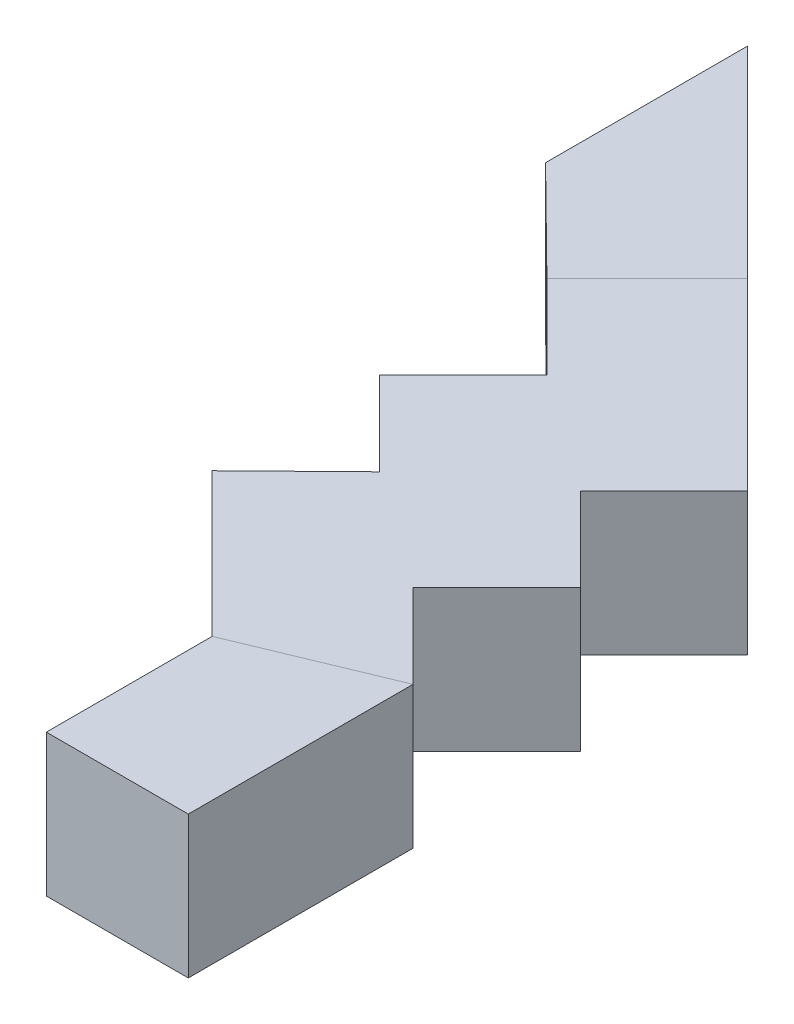
from build123d import *

# Parameters (mm, degrees)
BOSS_EXTRUDE1_DEPTH      = 600
CUT_EXTRUDE9_DEPTH       = 8723.868006427
CUT_EXTRUDE9_DEPTH_BACK  = 8723.868006427
CUT_EXTRUDE_THIN1_DEPTH  = 8723.868006427
CUT_EXTRUDE40_DEPTH      = 400
CUT_EXTRUDE42_DEPTH      = 8272.33671098
CUT_EXTRUDE42_DEPTH_BACK = 8272.33671098
CUT_EXTRUDE43_DEPTH      = 200
CUT_EXTRUDE44_DEPTH      = 8662.204945729
CUT_EXTRUDE44_DEPTH_BACK = 8662.204945729
SKETCH20_W               = 1000
SKETCH20_H               = 600
CUT_EXTRUDE45_DEPTH      = 600
CUT_EXTRUDE46_DEPTH      = 600
BOSS_EXTRUDE2_DEPTH      = 600
BOSS_EXTRUDE3_DEPTH      = 600
BOSS_EXTRUDE4_DEPTH      = 600
BOSS_EXTRUDE5_REACH      = 8720.017
SKETCH27_W               = 600.055718855
SKETCH27_H               = 600
SKETCH41_W               = 5944.592645119
SKETCH41_H               = 1845.640359894
CUT_EXTRUDE49_DEPTH      = 10020
SKETCH42_W               = 3231.101034248
SKETCH42_H               = 2243.42822902
CUT_EXTRUDE50_DEPTH      = 10020


with BuildPart() as part:
    # Sketch1 → Boss-Extrude1 (new body)
    with BuildSketch(Plane(origin=(0, 0, 0), x_dir=(1, 0, 0), z_dir=(0, 1, 0))):
        Polygon((0, 0), (-1000, 0), (-2062.518408918, -284.700949613), (-3015.146353081, -834.700949613), (-3792.963812386, -1612.518408918), (-4570.781271691, -2390.335868223), (-4695.045340403, -2485.687041782), (-5647.673284566, -3035.687041782), (-5792.381857505, -3095.627295285), (-6854.900266423, -3380.328244897), (-7010.191693484, -3400.772749124), (-8010.191693484, -3400.772749124), (-8010.191693484, -2800.772749124), (-7010.191693484, -2800.772749124), (-5947.673284566, -2516.071799511), (-4995.045340403, -1966.071799511), (-4217.227881098, -1188.254340206), (-3439.410421793, -410.436880901), (-3315.146353081, -315.085707342), (-2362.518408918, 234.914292658), (-2217.809835979, 294.854546161), (-1155.291427062, 579.555495773), (-1000, 600), (0, 600), align=None)
    extrude(amount=-BOSS_EXTRUDE1_DEPTH)

    # Sketch7 → Cut-Extrude9 (cut, two sides)
    with BuildSketch(Plane.XY) as cut_extrude9_sk:
        Polygon((-1000, 14081.643483175), (-1000, 0), (-1000, -600), (-2062.518408918, -400), (-3015.146353081, -400), (-3015.146353081, 0), (-3015.146353081, 14081.643483175), (-3015.146353081, 42244.930449524), (-1000, 42244.930449524), align=None)
    extrude(amount=CUT_EXTRUDE9_DEPTH, mode=Mode.SUBTRACT)
    extrude(cut_extrude9_sk.sketch, amount=-CUT_EXTRUDE9_DEPTH_BACK, mode=Mode.SUBTRACT)


with BuildPart() as cut_extrude9_piece_1:
    # of the separate pieces the step leaves, piece 1, a body of its own (cut_extrude9_pieces)
    add(part.part.solids().sort_by_distance((-2062.518408918, -400, 284.700949613))[0])

    # Sketch14 → Cut-Extrude40 (cut)
    with BuildSketch(Plane(origin=(0, -400, 0), x_dir=(1, 0, 0), z_dir=(0, 1, 0))):
        Polygon((-3015.146353081, -834.700949613), (-3439.410421793, -410.436880901), (-3315.146353081, -315.085707342), (-3015.146353081, -141.880626585), align=None)
    extrude(amount=CUT_EXTRUDE40_DEPTH, mode=Mode.SUBTRACT)

    # Sketch17 → Cut-Extrude42 (cut, two sides)
    with BuildSketch(Plane(origin=(-1090.222701734, 0, -1090.222701734), x_dir=(0.7071067811865475, 0, -0.7071067811865477), z_dir=(0.7071067811865477, 0, 0.7071067811865475))) as cut_extrude42_sk:
        Polygon((-4922.253134267, 10770.157285422), (-4922.253134267, 0), (-4922.253134267, -200), (-2722.253134267, -400), (-2722.253134267, 0), (-2722.253134267, 10770.157285422), (-2722.253134267, 32310.471856265), (-4922.253134267, 32310.471856265), align=None)
    extrude(amount=CUT_EXTRUDE42_DEPTH, mode=Mode.SUBTRACT)
    extrude(cut_extrude42_sk.sketch, amount=-CUT_EXTRUDE42_DEPTH_BACK, mode=Mode.SUBTRACT)

    # Sketch18 → Cut-Extrude43 (cut)
    with BuildSketch(Plane(origin=(0, 0, 0), x_dir=(1, 0, 0), z_dir=(0, 1, 0))):
        Polygon((-4570.781271691, -2390.335868223), (-4995.045340403, -1966.071799511), (-5947.673284566, -2516.071799511), (-5792.381857505, -3095.627295285), (-5647.673284566, -3035.687041782), (-4695.045340403, -2485.687041782), align=None)
    extrude(amount=-CUT_EXTRUDE43_DEPTH, mode=Mode.SUBTRACT)

    # Sketch19 → Cut-Extrude44 (cut, two sides)
    with BuildSketch(Plane(origin=(385.890813578, 0, 1440.164122449), x_dir=(0.9659258262890701, 0, -0.2588190451025142), z_dir=(0.2588190451025142, 0, 0.9659258262890701))) as cut_extrude44_sk:
        Polygon((-7496.218532451, 0), (-6396.218532451, -200), (-6396.218532451, 0), align=None)
    extrude(amount=CUT_EXTRUDE44_DEPTH, mode=Mode.SUBTRACT)
    extrude(cut_extrude44_sk.sketch, amount=-CUT_EXTRUDE44_DEPTH_BACK, mode=Mode.SUBTRACT)

    # Sketch20 → Cut-Extrude45 (cut)
    with BuildSketch(Plane(origin=(0, 0, 0), x_dir=(1, 0, 0), z_dir=(0, 1, 0))):
        with Locations((-7510.191693484, -3100.772749124)):
            Rectangle(SKETCH20_W, SKETCH20_H)
    extrude(amount=-CUT_EXTRUDE45_DEPTH, mode=Mode.SUBTRACT)

    # Sketch22 → Boss-Extrude2 (add)
    with BuildSketch(Plane(origin=(0, 0, 0), x_dir=(1, 0, 0), z_dir=(0, 1, 0))):
        Polygon((-7010.191693484, -3400.772749124), (-7610.191693484, -3400.772749124), (-7610.191693484, -2099.772749124), (-7010.191693484, -1850.772749124), (-7010.191693484, -2800.772749124), align=None)
    extrude(amount=-BOSS_EXTRUDE2_DEPTH)

    # Sketch23 → Boss-Extrude3 (add)
    with BuildSketch(Plane(origin=(0, 0, 0), x_dir=(1, 0, 0), z_dir=(0, 1, 0))):
        Polygon((-7010.191693484, -1850.772749124), (-7363.745084077, -1497.219358531), (-7010.191693484, -1143.665967937), (-7363.745084077, -790.112577344), (-7010.191693484, -436.559186751), (-7369.52720003, -77.223680205), (-7793.791268742, 347.040388507), (-7858.719830908, 270.547594436), (-8212.273221501, -83.005796158), (-7858.719830908, -436.559186751), (-8212.273221501, -790.112577344), (-7858.719830908, -1143.665967937), (-8216.472118741, -1493.492323867), (-7610.191693484, -2099.772749124), align=None)
    extrude(amount=-BOSS_EXTRUDE3_DEPTH)

    # Sketch27 → Boss-Extrude5 (add, up to next)
    with BuildSketch(Plane(origin=(-4176.549949048, 0, -4064.239704482), x_dir=(0.6974051569050131, 0, -0.7166770870638283), z_dir=(0.7166770870638283, 0, 0.6974051569050131)), mode=Mode.PRIVATE) as boss_extrude5_sk1:
        with Locations((-5486.74218736, -300)):
            Rectangle(SKETCH27_W, SKETCH27_H)
    boss_extrude5_tool1 = extrude(boss_extrude5_sk1.sketch, amount=BOSS_EXTRUDE5_REACH, mode=Mode.PRIVATE) - cut_extrude9_piece_1.part


with BuildPart() as cut_extrude9_piece_2:
    # of the separate pieces the step leaves, piece 2, a body of its own (cut_extrude9_pieces)
    add(part.part.solids().sort_by_distance((0, 0, 0))[0])

    # Sketch8 → Cut-Extrude-Thin1 (cut, through all)
    with BuildSketch(Plane.XY):
        Polygon((-1000, 0), (-1000, -600), (0, -600), (0, 0), (-10, 0), (-10, -590), (-990, -590), (-990, 0), align=None)
        Polygon((-4695.045340403, 0), (-4695.045340403, -200), (-4570.781271691, -200), (-3015.146353081, -400), (-3013.871199655, -390.081634019), (-4570.141081915, -190), (-4685.045340403, -190), (-4685.045340403, 0), align=None)
    extrude(amount=-CUT_EXTRUDE_THIN1_DEPTH, mode=Mode.SUBTRACT)

    # Sketch21 → Cut-Extrude46 (cut)
    with BuildSketch(Plane(origin=(0, 0, 0), x_dir=(1, 0, 0), z_dir=(0, 1, 0))):
        Polygon((0, 0), (-10, 600), (-990, 600), (-1000, 0), align=None)
    extrude(amount=-CUT_EXTRUDE46_DEPTH, mode=Mode.SUBTRACT)


with BuildPart() as body_2:
    # Sketch24 → Boss-Extrude4 (new body)
    with BuildSketch(Plane(origin=(0, 0, 0), x_dir=(1, 0, 0), z_dir=(0, 1, 0))):
        Polygon((-8212.273221501, -83.005796158), (-8639.443107058, 338.362406502), (-8639.443107058, 1192.692226823), (-7793.791268742, 347.040388507), align=None)
    extrude(amount=-BOSS_EXTRUDE4_DEPTH)


with BuildPart() as cut_extrude9_piece_1_1:
    add(cut_extrude9_piece_1.part)

    add(body_2.part)  # Boss-Extrude5 merges body 2
    add(boss_extrude5_tool1.solids().sort_by_distance((-8003.032245, -300, -132.017296))[0])

    # Sketch41 → Cut-Extrude49 (cut)
    with BuildSketch(Plane(origin=(-7010.191693484, 0, 0), x_dir=(0, 0, -1), z_dir=(1, 0, 0))):
        with Locations((-1423.304755155, -22.132559393)):
            Rectangle(SKETCH41_W, SKETCH41_H)
    extrude(amount=CUT_EXTRUDE49_DEPTH, mode=Mode.SUBTRACT)

    # Sketch42 → Cut-Extrude50 (cut)
    with BuildSketch(Plane.XY.offset(2800.772749124)):
        with Locations((-8030.549378888, -410.822906144)):
            Rectangle(SKETCH42_W, SKETCH42_H)
    extrude(amount=CUT_EXTRUDE50_DEPTH, mode=Mode.SUBTRACT)


solid = cut_extrude9_piece_1_1.part
